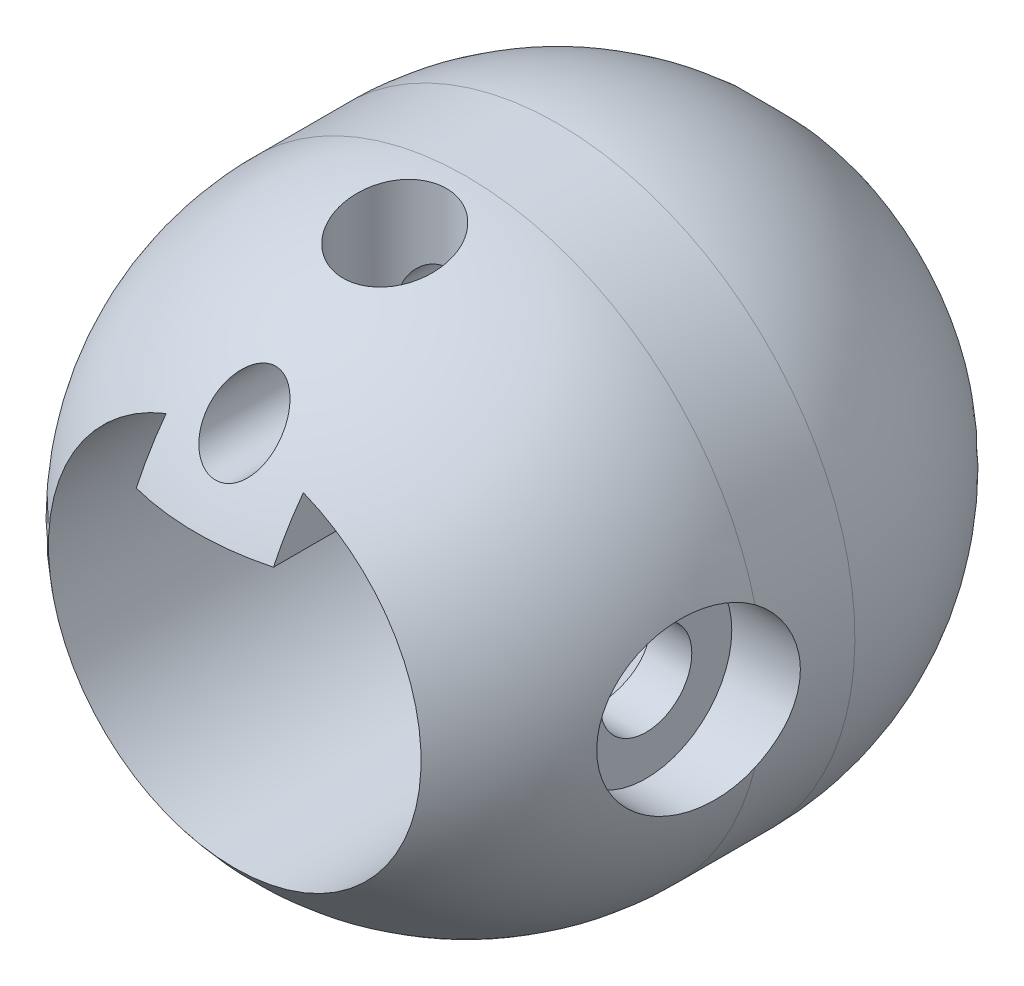
from build123d import *

# Parameters (mm, degrees)
BODY_ANGLE                  = 180
HOLE_FOR_HANDLE_DEPTH       = 12.258330249
SKETCH6_R                   = 1.1303
F_5_40_SET_SCREW_HOLE_DEPTH = 7
SKETCH8_R                   = 0.75
HOLE_FOR_CABLE_DEPTH        = 7
BOSS_EXTRUDE1_START         = 2
SKETCH9_R                   = 0.75
BOSS_EXTRUDE1_DEPTH         = 2
SKETCH10_R                  = 0.8
F_2X0_4_SCREW_HOLE_DEPTH    = 16.69059356
SKETCH11_R                  = 1
CUT_EXTRUDE5_DEPTH          = 4
SKETCH12_R                  = 1.875
CUT_EXTRUDE6_DEPTH          = 1.5
REVOLVE4_ANGLE              = 180
SKETCH14_R                  = 0.75
CUT_EXTRUDE7_DEPTH          = 13.128081245


with BuildPart() as part:
    # Sketch3 → body (revolve)
    with BuildSketch(Plane.XY):
        with BuildLine():
            Line((0, 6.5), (0, -6.5))
            ThreePointArc((0, -6.5), (6.5, 0), (0, 6.5))
        make_face()
    revolve(axis=Axis((0, 6.5, 0), (0, -1, 0)), revolution_arc=BODY_ANGLE)

    # Sketch5 → hole for handle (cut, through all)
    with BuildSketch(Plane(origin=(0, 0, 0), x_dir=(-1, 0, 0), z_dir=(0, 0, -1))):
        with BuildLine():
            Line((1.5, 3.688881761), (1.5, 2.702827207))
            Line((1.5, 2.702827207), (-1.5, 2.702827207))
            Line((-1.5, 2.702827207), (-1.5, 3.688881761))
            Line((-1.5, 3.688881761), (-1.5, 3.788881761))
            ThreePointArc((-1.5, 3.788881761), (0, -4.075), (1.5, 3.788881761))
            Line((1.5, 3.788881761), (1.5, 3.688881761))
        make_face()
    extrude(amount=-HOLE_FOR_HANDLE_DEPTH, mode=Mode.SUBTRACT)

    # Sketch6 → 5-40 set screw hole (cut)
    with BuildSketch(Plane(origin=(0, 6.5, 0), x_dir=(1, 0, 0), z_dir=(0, 1, 0))):
        with Locations((0, -1.564027547)):
            Circle(SKETCH6_R)
    extrude(amount=-F_5_40_SET_SCREW_HOLE_DEPTH, mode=Mode.SUBTRACT)

    # Sketch8 → hole for cable (cut)
    with BuildSketch(Plane(origin=(0, 0, 0), x_dir=(-1, 0, 0), z_dir=(0, 0, -1))):
        with Locations((0, 4.237225844)):
            Circle(SKETCH8_R)
    extrude(amount=-HOLE_FOR_CABLE_DEPTH, mode=Mode.SUBTRACT)

    # Sketch9 → Boss-Extrude1 (add)
    with BuildSketch(Plane(origin=(0, 0, 0), x_dir=(-1, 0, 0), z_dir=(0, 0, -1)).offset(BOSS_EXTRUDE1_START)):
        with BuildLine():
            ThreePointArc((6.5, 0), (4.596194078, 4.596194078), (0, 6.5))
            ThreePointArc((0, 6.5), (-6.5, 0), (0, -6.5))
            ThreePointArc((0, -6.5), (4.596194078, -4.596194078), (6.5, 0))
        make_face()
        with BuildLine():
            Line((-1.5, 3.788881761), (-1.5, 2.702827207))
            Line((-1.5, 2.702827207), (1.5, 2.702827207))
            Line((1.5, 2.702827207), (1.5, 3.788881761))
            ThreePointArc((1.5, 3.788881761), (0, -4.075), (-1.5, 3.788881761))
        make_face(mode=Mode.SUBTRACT)
        with Locations((0, 4.237225844)):
            Circle(SKETCH9_R, mode=Mode.SUBTRACT)
    extrude(amount=-BOSS_EXTRUDE1_DEPTH)

    # Sketch10 → 2X0.4 screw hole (cut, through all)
    with BuildSketch(Plane(origin=(6.5, 0, 0), x_dir=(0, 0, -1), z_dir=(1, 0, 0))):
        with Locations((-1.067713855, 0)):
            Circle(SKETCH10_R)
    extrude(amount=-F_2X0_4_SCREW_HOLE_DEPTH, mode=Mode.SUBTRACT)

    # Sketch11 → Cut-Extrude5 (cut)
    with BuildSketch(Plane(origin=(6.5, 0, 0), x_dir=(0, 0, -1), z_dir=(1, 0, 0))):
        with Locations((-1.067713855, 0)):
            Circle(SKETCH11_R)
    extrude(amount=-CUT_EXTRUDE5_DEPTH, mode=Mode.SUBTRACT)

    # Sketch12 → Cut-Extrude6 (cut)
    with BuildSketch(Plane(origin=(6.5, 0, 0), x_dir=(0, 0, -1), z_dir=(1, 0, 0))):
        with Locations((-1.067713855, 0)):
            Circle(SKETCH12_R)
    extrude(amount=-CUT_EXTRUDE6_DEPTH, mode=Mode.SUBTRACT)

    # Sketch13 → Revolve4 (revolve)
    with BuildSketch(Plane(origin=(0, 0, -2), x_dir=(-1, 0, 0), z_dir=(0, 0, -1))):
        with BuildLine():
            Line((0, 6.5), (0, -6.5))
            ThreePointArc((0, -6.5), (6.5, 0), (0, 6.5))
        make_face()
    revolve(axis=Axis((0, 6.5, -2), (0, -1, 0)), revolution_arc=REVOLVE4_ANGLE)

    # Sketch14 → Cut-Extrude7 (cut, through all)
    with BuildSketch(Plane.XY.offset(-2)):
        with Locations((0, 4.237225844)):
            Circle(SKETCH14_R)
        with BuildLine():
            Line((1.5, 3.788881761), (1.5, 2.702827207))
            Line((1.5, 2.702827207), (-1.5, 2.702827207))
            Line((-1.5, 2.702827207), (-1.5, 3.788881761))
            ThreePointArc((-1.5, 3.788881761), (0, -4.075), (1.5, 3.788881761))
        make_face()
    extrude(amount=-CUT_EXTRUDE7_DEPTH, mode=Mode.SUBTRACT)


solid = part.part
